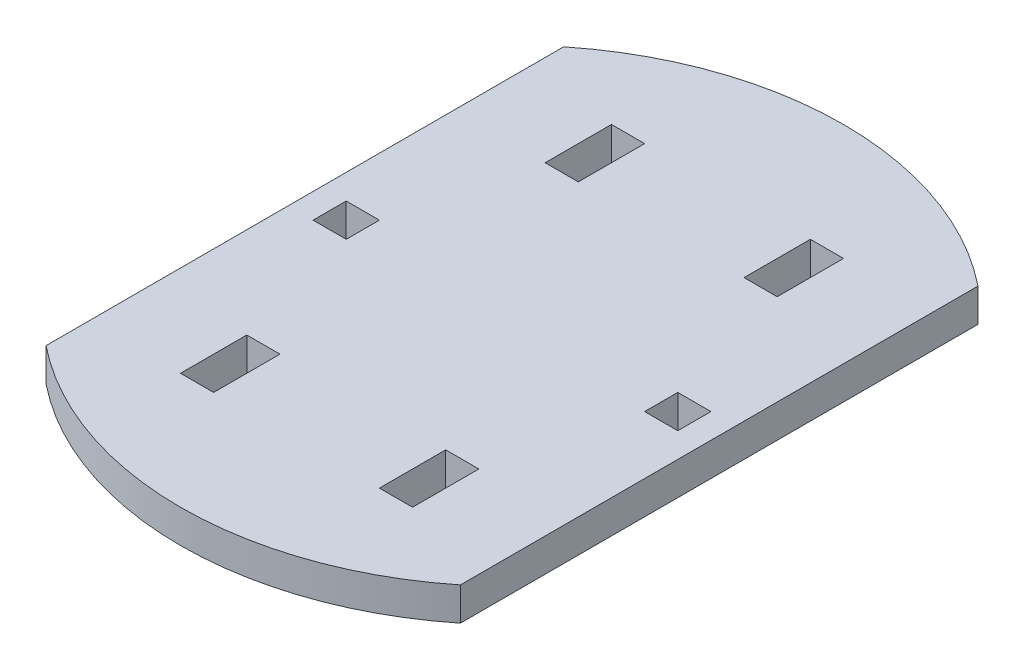
from build123d import *

# Parameters (mm, degrees)
SKETCH1_W           = 4
SKETCH1_H           = 8
SKETCH1_H_2         = 4
BOSS_EXTRUDE1_DEPTH = 4


with BuildPart() as part:
    # Sketch1 → Boss-Extrude1 (new body)
    with BuildSketch(Plane(origin=(0, 0, 0), x_dir=(1, 0, 0), z_dir=(0, 1, 0))):
        with BuildLine():
            ThreePointArc((25, 31.224989992), (0, 40), (-25, 31.224989992))
            Line((-25, 31.224989992), (-25, -31.224989992))
            ThreePointArc((-25, -31.224989992), (0, -40), (25, -31.224989992))
            Line((25, -31.224989992), (25, 31.224989992))
        make_face()
        with Locations((-12, -22)):
            Rectangle(SKETCH1_W, SKETCH1_H, mode=Mode.SUBTRACT)
        with Locations((12, -22)):
            Rectangle(SKETCH1_W, SKETCH1_H, mode=Mode.SUBTRACT)
        with Locations((-20, 0)):
            Rectangle(SKETCH1_W, SKETCH1_H_2, mode=Mode.SUBTRACT)
        with Locations((-12, 22)):
            Rectangle(SKETCH1_W, SKETCH1_H, mode=Mode.SUBTRACT)
        with Locations((20, 0)):
            Rectangle(SKETCH1_W, SKETCH1_H_2, mode=Mode.SUBTRACT)
        with Locations((12, 22)):
            Rectangle(SKETCH1_W, SKETCH1_H, mode=Mode.SUBTRACT)
    extrude(amount=BOSS_EXTRUDE1_DEPTH)


solid = part.part
